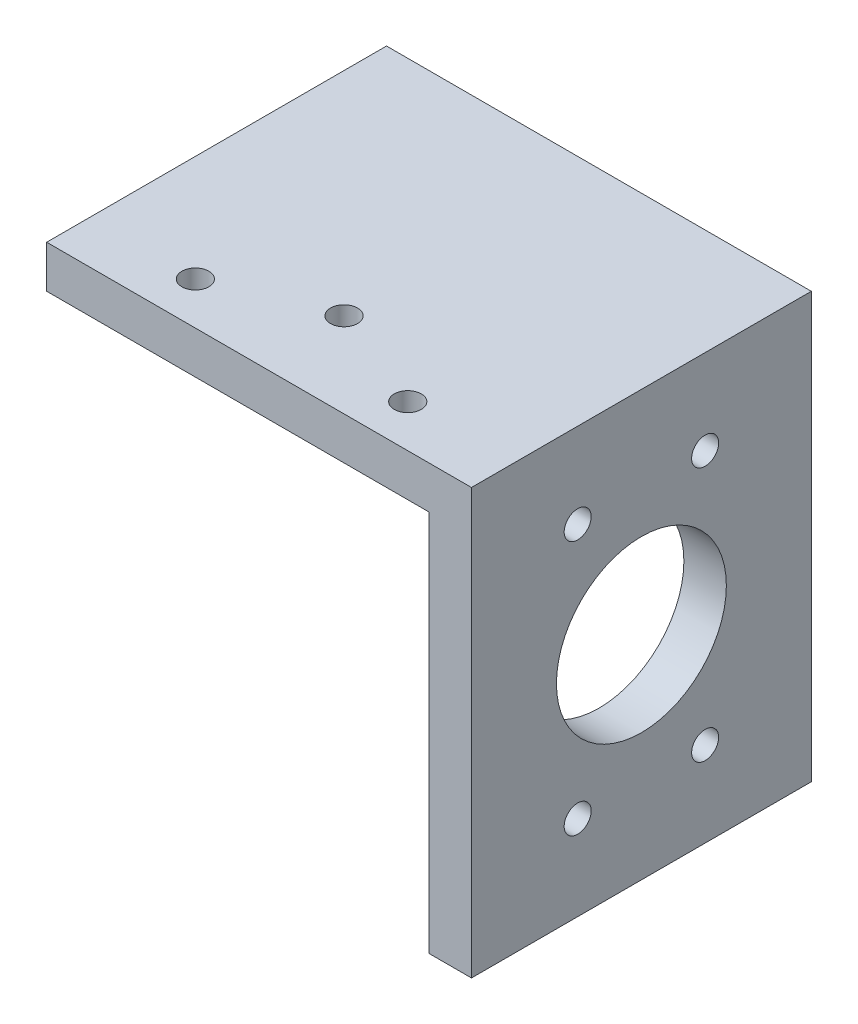
from build123d import *

# Parameters (mm, degrees)
BOSS_EXTRUDE1_DEPTH        = 50.8
CUT_EXTRUDE1_REACH         = 65.5
SKETCH2_R                  = 12.7
F_10_32_TAPPED_HOLE1_D     = 4.0386
F_10_32_TAPPED_HOLE1_DEPTH = 6.35
F_10_32_TAPPED_HOLE2_D     = 4.0386
F_10_32_TAPPED_HOLE2_DEPTH = 6.35


with BuildPart() as part:
    # Sketch1 → Boss-Extrude1 (new body)
    with BuildSketch(Plane.XY):
        Polygon((0, 0), (63.5, 0), (63.5, -63.5), (57.15, -63.5), (57.15, -6.35), (0, -6.35), align=None)
    extrude(amount=BOSS_EXTRUDE1_DEPTH)

    # Sketch2 → Cut-Extrude1 (cut, up to next)
    with BuildSketch(Plane(origin=(63.5, 0, 0), x_dir=(0, 0, -1), z_dir=(1, 0, 0)), mode=Mode.PRIVATE) as cut_extrude1_sk1:
        with Locations((-25.4, -31.75)):
            Circle(SKETCH2_R)
    cut_extrude1_tool1 = extrude(cut_extrude1_sk1.sketch, amount=-CUT_EXTRUDE1_REACH, mode=Mode.PRIVATE) & part.part
    add(cut_extrude1_tool1.solids().sort_by_distance((63.5, -31.75, 25.4))[0], mode=Mode.SUBTRACT)

    # #10-32 Tapped Hole1
    with Locations(Plane(origin=(63.5, 0, 0), x_dir=(0, 0, -1), z_dir=(1, 0, 0))):
        with Locations((-34.925, -50.8), (-15.875, -50.8), (-34.925, -12.7), (-15.875, -12.7)):
            Hole(F_10_32_TAPPED_HOLE1_D / 2, depth=F_10_32_TAPPED_HOLE1_DEPTH)

    # #10-32 Tapped Hole2
    with Locations(Plane(origin=(0, 0, 0), x_dir=(1, 0, 0), z_dir=(0, 1, 0))):
        with Locations((47.625, -44.45), (31.75, -38.1), (15.875, -44.45)):
            Hole(F_10_32_TAPPED_HOLE2_D / 2, depth=F_10_32_TAPPED_HOLE2_DEPTH)


solid = part.part
